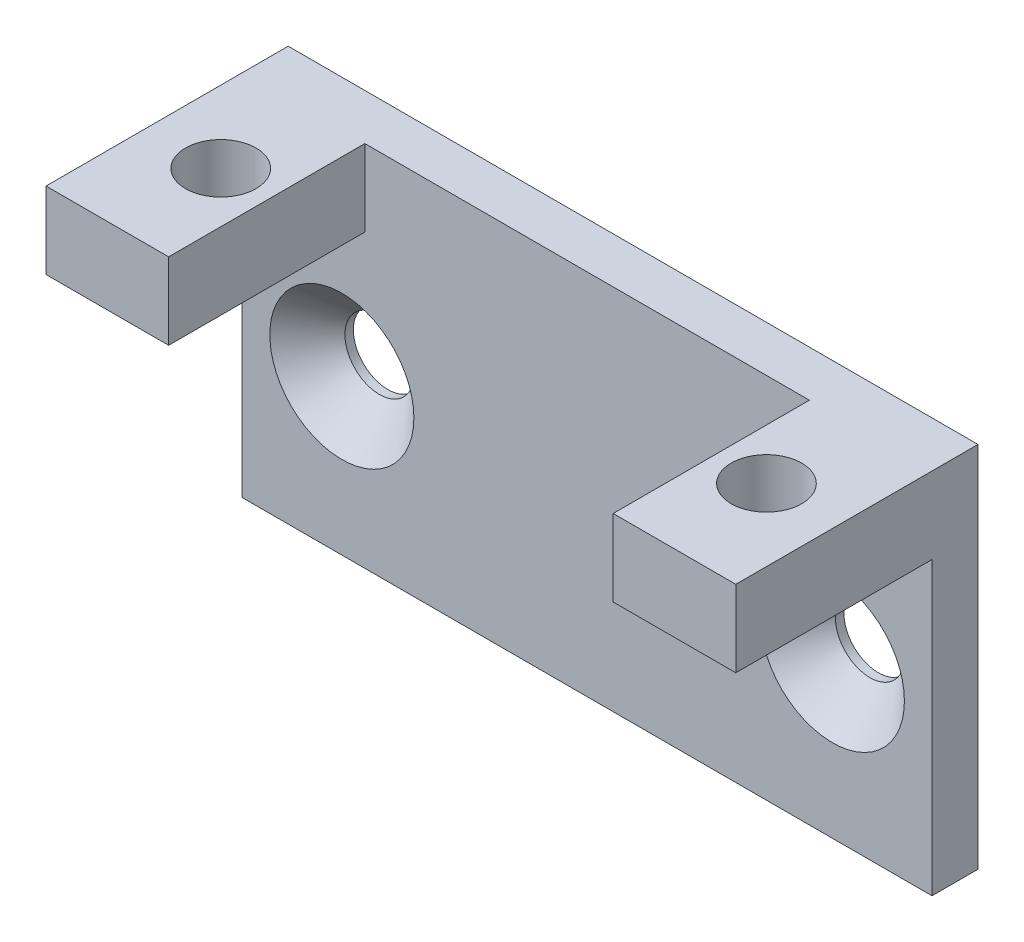
from build123d import *

# Parameters (mm, degrees)
ESQUISSE1_W                = 45
ESQUISSE1_H                = 19
BOSS_EXTRU_1_DEPTH         = 3
R_P_TITION_LIN_AIRE3_COUNT = 2
R_P_TITION_LIN_AIRE3_PITCH = 32
ESQUISSE7_W                = 15.8
ESQUISSE7_H                = 5
BOSS_EXTRU_2_DEPTH         = 45
ESQUISSE8_W                = 29
ESQUISSE8_H                = 12.8
ENL_V_MAT_EXTRU_4_DEPTH    = 3
ESQUISSE8_5_W              = 29
ESQUISSE8_5_H              = 12.8
ENL_V_MAT_EXTRU_5_DEPTH    = 6
ESQUISSE9_R                = 2.3
ENL_V_MAT_EXTRU_6_DEPTH    = 10


with BuildPart() as part:
    # Esquisse1 → Boss.-Extru.1 (new body)
    with BuildSketch(Plane.XY):
        with Locations((22.5, 9.5)):
            Rectangle(ESQUISSE1_W, ESQUISSE1_H)
    extrude(amount=BOSS_EXTRU_1_DEPTH)

    # Esquisse5 → Fraisage pour vis _ t_te frais_e M42 (revolve, cut)
    with BuildSketch(Plane(origin=(38.5, 10.1, 3), x_dir=(0, -1, 0), z_dir=(1, 0, 0))):
        Polygon((0, 0), (0, 3), (2.25, 3), (2.25, 2.45), (4.7, 0), align=None)
    fraisage_pour_vis_t_te_frais_e_m42 = revolve(axis=Axis((38.5, 10.1, 9.35), (0, 0, -1)), mode=Mode.SUBTRACT)

    # R_p_tition lin_aire3: Fraisage pour vis _ t_te frais_e M42 ×2
    with Locations(*[(-i * R_P_TITION_LIN_AIRE3_PITCH, 0, 0) for i in range(1, R_P_TITION_LIN_AIRE3_COUNT)]):
        add(fraisage_pour_vis_t_te_frais_e_m42, mode=Mode.SUBTRACT)

    # Esquisse7 → Boss.-Extru.2 (add)
    with BuildSketch(Plane(origin=(45, 19, 0), x_dir=(0, 0, 1), z_dir=(-1, 0, 0))):
        with Locations((7.9, 2.5)):
            Rectangle(ESQUISSE7_W, ESQUISSE7_H)
    extrude(amount=BOSS_EXTRU_2_DEPTH)

    # Esquisse8 → Enl_v. mat.-Extru.4 (cut)
    with BuildSketch(Plane.XZ.offset(-19)):
        with Locations((22.5, 9.4)):
            Rectangle(ESQUISSE8_W, ESQUISSE8_H)
    extrude(amount=-ENL_V_MAT_EXTRU_4_DEPTH, mode=Mode.SUBTRACT)

    # Esquisse8_5 → Enl_v. mat.-Extru.5 (cut, through all)
    with BuildSketch(Plane.XZ.offset(-19)):
        with Locations((22.5, 9.4)):
            Rectangle(ESQUISSE8_5_W, ESQUISSE8_5_H)
    extrude(amount=-ENL_V_MAT_EXTRU_5_DEPTH, mode=Mode.SUBTRACT)

    # Esquisse9 → Enl_v. mat.-Extru.6 (cut)
    with BuildSketch(Plane(origin=(0, 24, 0), x_dir=(1, 0, 0), z_dir=(0, 1, 0))):
        with Locations((40.3, -9.1)):
            Circle(ESQUISSE9_R)
    enl_v_mat_extru_6 = extrude(amount=-ENL_V_MAT_EXTRU_6_DEPTH, mode=Mode.SUBTRACT)

    # Sym_trie1: Enl_v. mat.-Extru.6 across plane
    add(enl_v_mat_extru_6.mirror(Plane(origin=(22.5, 0, 0), x_dir=(0, 0, 1), z_dir=(1, 0, 0))), mode=Mode.SUBTRACT)


solid = part.part
